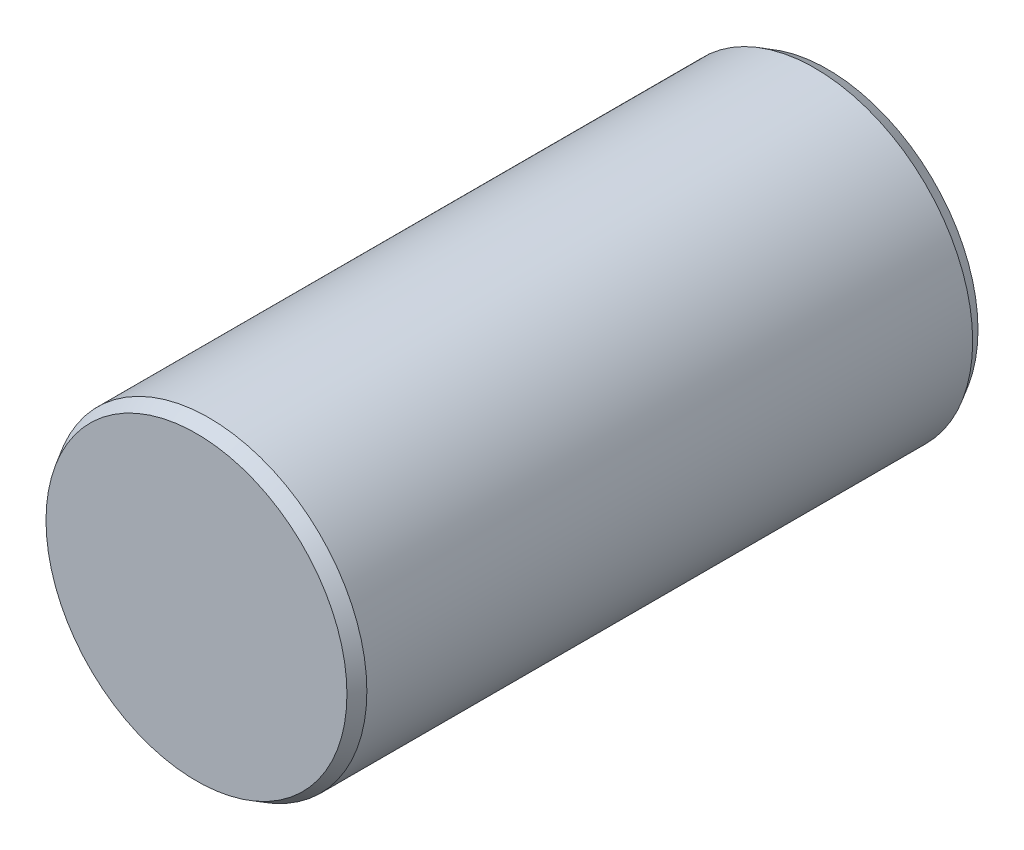
from build123d import *

# Parameters (mm, degrees)
ESQUISSE1_R        = 2.5
BOSS_EXTRU_1_DEPTH = 5
CHANFREIN1_SIZE    = 0.2
CHANFREIN1_SIZE2   = 0.115470054


with BuildPart() as part:
    # Esquisse1 → Boss.-Extru.1 (new body, symmetric)
    with BuildSketch(Plane.XY):
        Circle(ESQUISSE1_R)
    extrude(amount=BOSS_EXTRU_1_DEPTH, both=True)

    # Chanfrein1
    chanfrein1_edges = [part.edges().sort_by_distance(p)[0] for p in [
        (-2.5, 0, -5),
        (-2.5, 0, 5),
    ]]
    chanfrein1_side = [part.faces().sort_by_distance(p)[0] for p in [
        (-2.5, 0, 0),
    ]]
    chamfer(chanfrein1_edges, length=CHANFREIN1_SIZE, length2=CHANFREIN1_SIZE2, reference=chanfrein1_side[0])


solid = part.part
